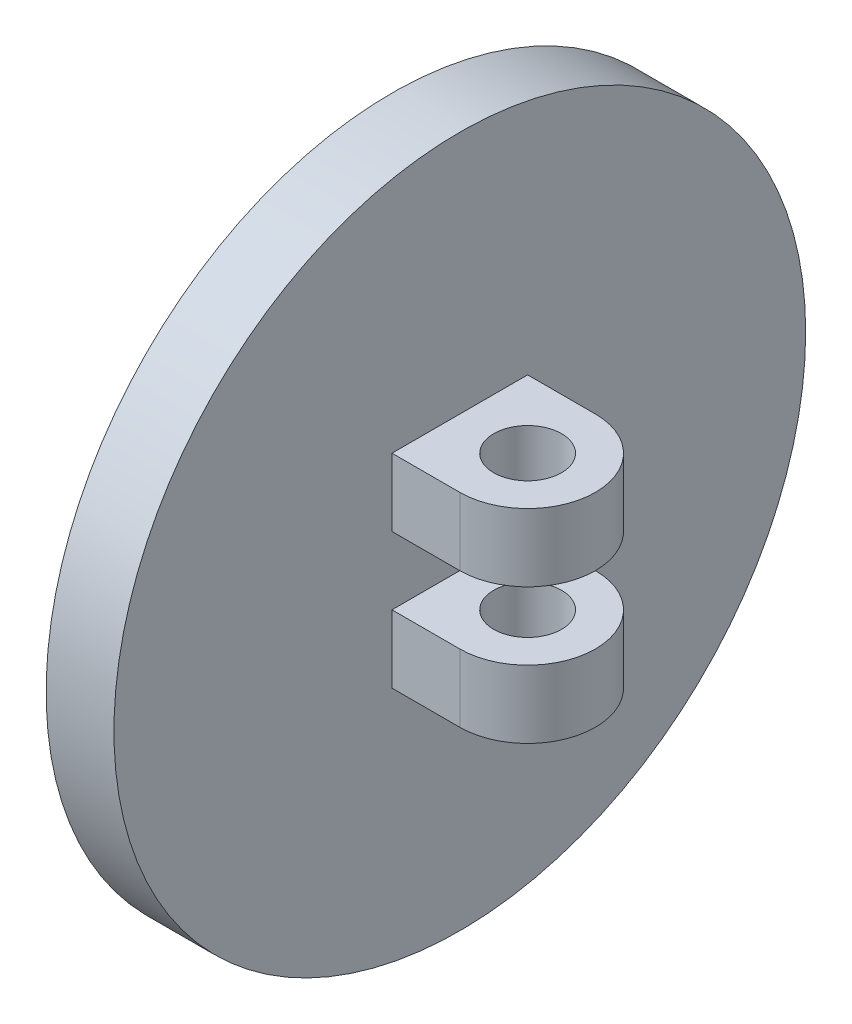
from build123d import *

# Parameters (mm, degrees)
SKETCH1_R           = 5.1
BOSS_EXTRUDE1_DEPTH = 1
BOSS_EXTRUDE2_START = 0.5
SKETCH2_R           = 0.5
BOSS_EXTRUDE2_DEPTH = 1


with BuildPart() as part:
    # Sketch1 → Boss-Extrude1 (new body)
    with BuildSketch(Plane(origin=(0, 0, 0), x_dir=(0, 0, -1), z_dir=(1, 0, 0))):
        Circle(SKETCH1_R)
    extrude(amount=BOSS_EXTRUDE1_DEPTH)

    # Sketch2 → Boss-Extrude2 (add)
    with BuildSketch(Plane(origin=(0, 0, 0), x_dir=(1, 0, 0), z_dir=(0, 1, 0)).offset(BOSS_EXTRUDE2_START)):
        with BuildLine():
            Line((1, 1), (2, 1))
            ThreePointArc((2, 1), (3, 0), (2, -1))
            Line((2, -1), (1, -1))
            Line((1, -1), (1, 1))
        make_face()
        with Locations((2, 0)):
            Circle(SKETCH2_R, mode=Mode.SUBTRACT)
    boss_extrude2 = extrude(amount=BOSS_EXTRUDE2_DEPTH)

    # Mirror1: Boss-Extrude2 across plane
    add(boss_extrude2.mirror(Plane.ZX))


solid = part.part
